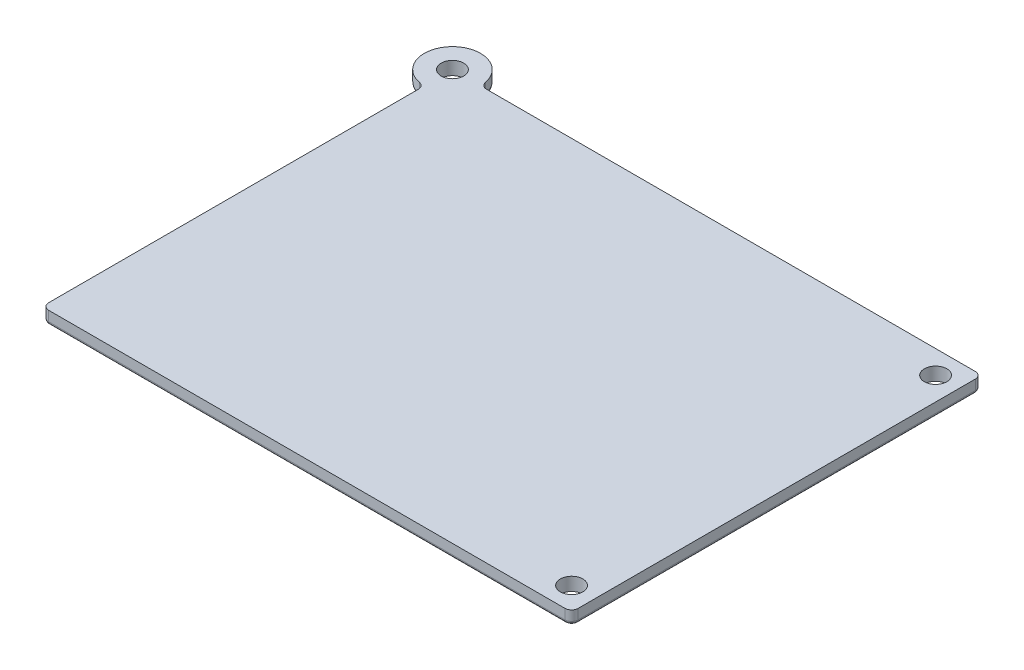
from build123d import *

# Parameters (mm, degrees)
MAIN_BODY_DEPTH        = 2
CORNERS_R              = 1
EDGE_2_R               = 0.5
LID_HOLES_DEPTH        = 57.609407345
LID_HOLES_DEPTH_BACK   = 57.609407345
SKETCH7_R              = 1.7
SKETCH4_R              = 2.325
BOSS_EXTRUDE3_DEPTH    = 1.6
FILLET3_R              = 0.05
LPATTERN5_COUNT        = 4
LPATTERN5_PITCH        = 8
FILLET3_OF_LPATTERN5_R = 0.05
SKETCH9_R              = 2.325
PEGS_DIAGONAL_DEPTH    = 1.6
FILLET6_R              = 0.05
LPATTERN6_COUNT        = 4
LPATTERN6_PITCH        = 8


with BuildPart() as part:
    # Sketch1 → Main Body (new body)
    with BuildSketch(Plane(origin=(0, 0, 0), x_dir=(1, 0, 0), z_dir=(0, 1, 0))):
        with BuildLine():
            Line((-40, -31), (40, -31))
            Line((40, -31), (40, 31))
            Line((40, 31), (-34.846117968, 31))
            ThreePointArc((-34.846117968, 31), (-35.482326978, 31.22848325), (-35.827809784, 31.80952381))
            ThreePointArc((-35.827809784, 31.80952381), (-43.00520382, 34.00520382), (-40.80952381, 26.827809784))
            ThreePointArc((-40.80952381, 26.827809784), (-40.22848325, 26.482326978), (-40, 25.846117968))
            Line((-40, 25.846117968), (-40, -31))
        make_face()
    extrude(amount=MAIN_BODY_DEPTH)

    # Corners
    corners_edges = [part.edges().sort_by_distance(p)[0] for p in [
        (-40, 1, 31),
        (40, 1, -31),
        (40, 1, 31),
    ]]
    fillet(corners_edges, radius=CORNERS_R)

    # Edge 2
    edge_2_edges = [part.edges().sort_by_distance(p)[0] for p in [
        (-39.707106781, 0, 30.707106781),
        (39.707106781, 0, -30.707106781),
        (39.707106781, 0, 30.707106781),
        (-40, 0, 2.076941016),
        (2.076941016, 0, -31),
        (40, 0, 0),
        (0, 0, 31),
        (-40.22848325, 0, -26.482326978),
        (-43.00520382, 0, -34.00520382),
        (-35.482326978, 0, -31.22848325),
    ]]
    fillet(edge_2_edges, radius=EDGE_2_R)

    # Sketch7 → Lid Holes (cut, two sides: drawn at the far end of the back side and taken through both)
    with BuildSketch(Plane(origin=(0, 0, 0), x_dir=(-1, 0, 0), z_dir=(0, -1, 0)).offset(-LID_HOLES_DEPTH_BACK)):
        with Locations((-36.5, 27.5)):
            Circle(SKETCH7_R)
        with Locations((-36.5, -27.5)):
            Circle(SKETCH7_R)
        with Locations((40, 31)):
            Circle(SKETCH7_R)
    extrude(amount=LID_HOLES_DEPTH + LID_HOLES_DEPTH_BACK, mode=Mode.SUBTRACT)

    # Sketch4 → Boss-Extrude3 (add)
    with BuildSketch(Plane(origin=(0, 0, 0), x_dir=(-1, 0, 0), z_dir=(0, -1, 0))):
        with Locations((-34.720642539, -19.604779645)):
            Circle(SKETCH4_R)
        with Locations((-28.898460478, -25.091326468)):
            Circle(SKETCH4_R)
    boss_extrude3 = extrude(amount=BOSS_EXTRUDE3_DEPTH)

    # Fillet3
    fillet3_edges = [part.edges().sort_by_distance(p)[0] for p in [
        (37.045642539, -1.6, 19.604779645),
        (31.223460478, -1.6, 25.091326468),
    ]]
    fillet(fillet3_edges, radius=FILLET3_R)

    # LPattern5: Boss-Extrude3 ×4
    with Locations(*[Vector(-0.6858183529273724, 0, -0.7277727576572142) * (i * LPATTERN5_PITCH) for i in range(1, LPATTERN5_COUNT)]):
        add(boss_extrude3)

    # Fillet3 of LPattern5
    fillet3_of_lpattern5_edges = [part.edges().sort_by_distance(p)[0] for p in [
        (31.559095716, -1.6, 13.782597583),
        (25.736913654, -1.6, 19.269144407),
        (26.072548892, -1.6, 7.960415522),
        (20.250366831, -1.6, 13.446962346),
        (20.586002069, -1.6, 2.138233461),
        (14.763820008, -1.6, 7.624780284),
    ]]
    fillet(fillet3_of_lpattern5_edges, radius=FILLET3_OF_LPATTERN5_R)

    # Sketch9 → Pegs _Diagonal (add)
    with BuildSketch(Plane(origin=(0, 0, 0), x_dir=(-1, 0, 0), z_dir=(0, -1, 0))):
        with Locations((28.209185967, -23.614923749)):
            Circle(SKETCH9_R)
        with Locations((34.102685906, -18.20505698)):
            Circle(SKETCH9_R)
    pegs_diagonal = extrude(amount=PEGS_DIAGONAL_DEPTH)

    # Fillet6
    fillet6_edges = [part.edges().sort_by_distance(p)[0] for p in [
        (-25.884185967, -1.6, 23.614923749),
        (-31.777685906, -1.6, 18.20505698),
    ]]
    fillet(fillet6_edges, radius=FILLET6_R)

    # LPattern6: Pegs _Diagonal ×4
    with Locations(*[Vector(0.6762333461397118, 0, -0.7366874924747189) * (i * LPATTERN6_PITCH) for i in range(1, LPATTERN6_COUNT)]):
        add(pegs_diagonal)


solid = part.part
